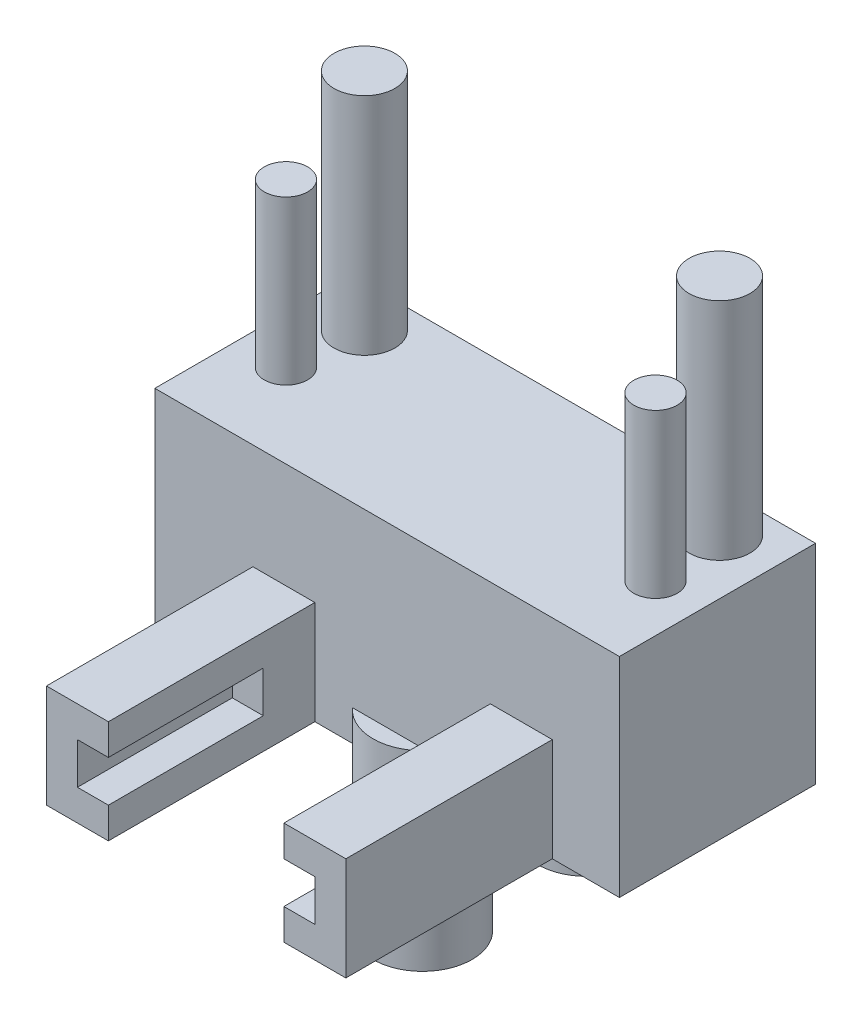
from build123d import *

# Parameters (mm, degrees)
SKETCH1_W                = 22.5
SKETCH1_H                = 7
BOSS_EXTRUDE1_DEPTH      = 1.5
SKETCH2_R                = 1.475
BOSS_EXTRUDE2_DEPTH      = 13.5
SKETCH3_R                = 1.05
BOSS_EXTRUDE3_DEPTH      = 10.5
SKETCH4_W                = 22.5
SKETCH4_H                = 2.5
SKETCH4_H_2              = 7
BOSS_EXTRUDE4_DEPTH      = 6
BOSS_EXTRUDE4_DEPTH_BACK = 1.5
SKETCH5_W                = 3
SKETCH5_H                = 10
BOSS_EXTRUDE6_DEPTH      = 5
SKETCH7_W                = 11.5
SKETCH7_H                = 2
CUT_EXTRUDE1_DEPTH       = 7.5
SKETCH8_W                = 22.5
SKETCH8_H                = 9.5
BOSS_EXTRUDE7_DEPTH      = 2.61
SKETCH9_R                = 2.4
BOSS_EXTRUDE8_DEPTH      = 7.76
BOSS_EXTRUDE8_DEPTH_BACK = 1.5


with BuildPart() as part:
    # Sketch1 → Boss-Extrude1 (new body)
    with BuildSketch(Plane(origin=(0, 0, 0), x_dir=(1, 0, 0), z_dir=(0, 1, 0))):
        with Locations((-28.93578967, -21.079480712)):
            Rectangle(SKETCH1_W, SKETCH1_H)
    extrude(amount=BOSS_EXTRUDE1_DEPTH)

    # Sketch2 → Boss-Extrude2 (add)
    with BuildSketch(Plane(origin=(0, 1.5, 0), x_dir=(1, 0, 0), z_dir=(0, 1, 0))):
        with Locations((-37.53578967, -19.579480712)):
            Circle(SKETCH2_R)
        with Locations((-20.33578967, -19.579480712)):
            Circle(SKETCH2_R)
    extrude(amount=BOSS_EXTRUDE2_DEPTH)

    # Sketch3 → Boss-Extrude3 (add)
    with BuildSketch(Plane(origin=(0, 1.5, 0), x_dir=(1, 0, 0), z_dir=(0, 1, 0))):
        with Locations((-37.88578967, -23.029480712)):
            Circle(SKETCH3_R)
        with Locations((-19.98578967, -23.029480712)):
            Circle(SKETCH3_R)
    extrude(amount=BOSS_EXTRUDE3_DEPTH)

    # Sketch4 → Boss-Extrude4 (add, two sides)
    with BuildSketch(Plane(origin=(0, 0, 0), x_dir=(-1, 0, 0), z_dir=(0, -1, 0))) as boss_extrude4_sk:
        with Locations((28.93578967, -25.829480712)):
            Rectangle(SKETCH4_W, SKETCH4_H)
        with Locations((28.93578967, -21.079480712)):
            Rectangle(SKETCH4_W, SKETCH4_H_2)
    extrude(amount=BOSS_EXTRUDE4_DEPTH)
    extrude(boss_extrude4_sk.sketch, amount=-BOSS_EXTRUDE4_DEPTH_BACK)

    # Sketch5 → Boss-Extrude6 (add)
    with BuildSketch(Plane(origin=(0, -6, 0), x_dir=(-1, 0, 0), z_dir=(0, -1, 0))):
        with Locations((33.93578967, -32.079480712)):
            Rectangle(SKETCH5_W, SKETCH5_H)
        with Locations((22.43578967, -32.079480712)):
            Rectangle(SKETCH5_W, SKETCH5_H)
    extrude(amount=-BOSS_EXTRUDE6_DEPTH)

    # Sketch7 → Cut-Extrude1 (cut)
    with BuildSketch(Plane.XY.offset(37.079480712)):
        with Locations((-28.18578967, -3.5)):
            Rectangle(SKETCH7_W, SKETCH7_H)
    extrude(amount=-CUT_EXTRUDE1_DEPTH, mode=Mode.SUBTRACT)

    # Sketch8 → Boss-Extrude7 (add)
    with BuildSketch(Plane(origin=(0, 1.5, 0), x_dir=(1, 0, 0), z_dir=(0, 1, 0))):
        with Locations((-28.93578967, -22.329480712)):
            Rectangle(SKETCH8_W, SKETCH8_H)
    extrude(amount=BOSS_EXTRUDE7_DEPTH)

    # Sketch9 → Boss-Extrude8 (add, two sides)
    with BuildSketch(Plane(origin=(0, -6, 0), x_dir=(-1, 0, 0), z_dir=(0, -1, 0))) as boss_extrude8_sk:
        with Locations((28.81078967, -25.489480712)):
            Circle(SKETCH9_R)
        with Locations((28.81078967, -17.519480712)):
            Circle(SKETCH9_R)
    extrude(amount=BOSS_EXTRUDE8_DEPTH)
    extrude(boss_extrude8_sk.sketch, amount=-BOSS_EXTRUDE8_DEPTH_BACK)


solid = part.part
